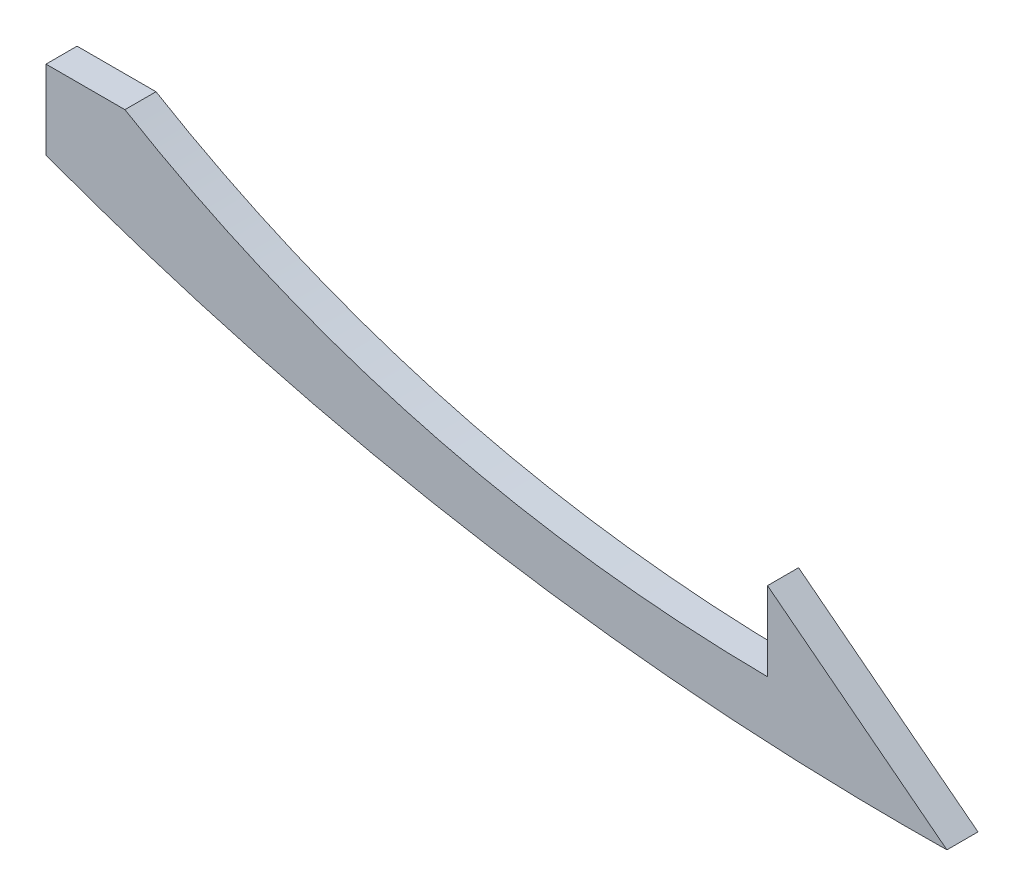
from build123d import *

# Parameters (mm, degrees)
BOSS_EXTRUDE1_DEPTH = 5


with BuildPart() as part:
    # Sketch1 → Boss-Extrude1 (new body)
    with BuildSketch(Plane.XY):
        with BuildLine():
            Line((0, -6.35), (0, 6.35))
            Line((0, 6.35), (12.7, 6.35))
            add(Edge.make_bspline(
                [(116.09390226, -20.974913526), (57.782450288, -20.453591086), (12.7, 6.35)],
                knots=[0, 0, 0, 0.666344137, 0.666344137, 0.666344137], degree=2))
            Line((116.09390226, -20.974913526), (116.09390226, -8.274913526))
            Line((116.09390226, -8.274913526), (144.960512242, -30.660512242))
            add(Edge.make_bspline(
                [(144.960512242, -30.660512242), (68.411482742, -31.717840837), (0, -6.35)],
                knots=[0, 0, 0, 0.71155061, 0.71155061, 0.71155061], degree=2))
        make_face()
    extrude(amount=BOSS_EXTRUDE1_DEPTH)


solid = part.part
